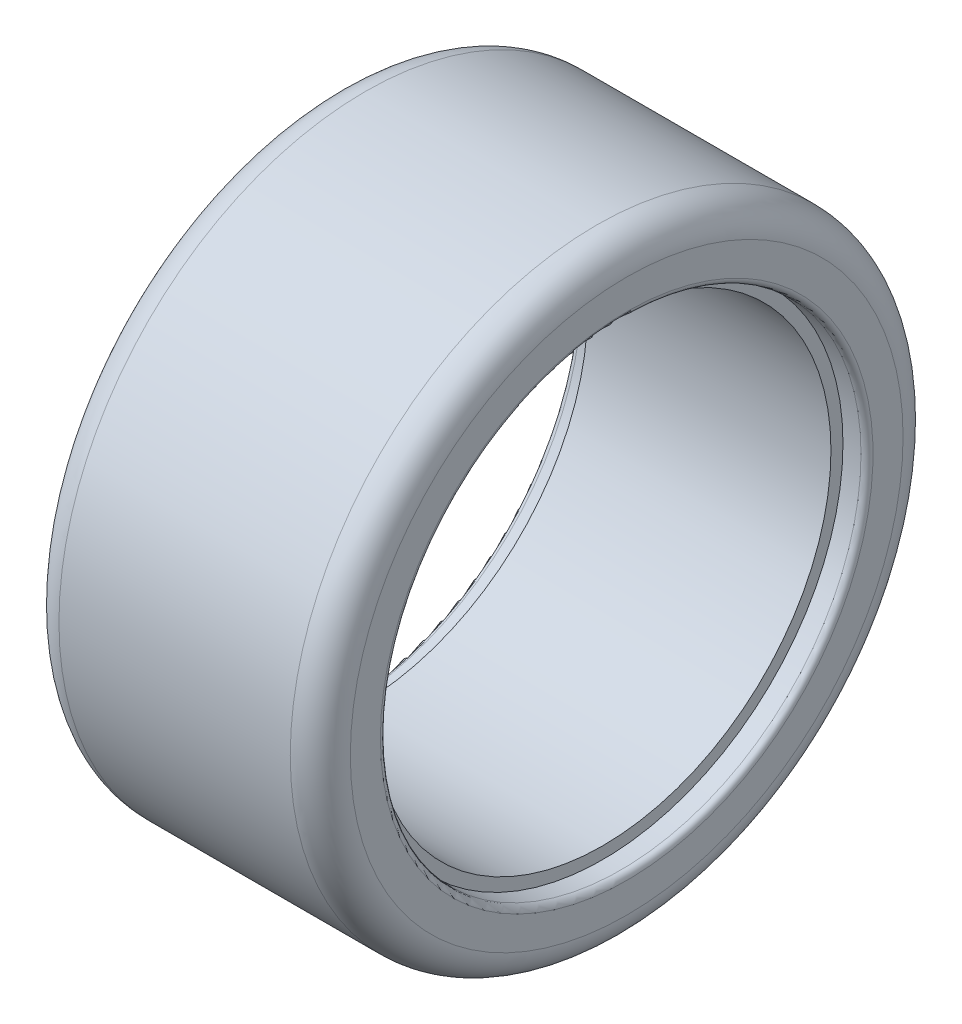
from build123d import *

# Parameters (mm, degrees)
FILLET1_R = 2.5
FILLET2_R = 0.5


with BuildPart() as part:
    # Sketch1 → Revolve1 (revolve)
    with BuildSketch(Plane(origin=(0, 0, 0), x_dir=(1, 0, 0), z_dir=(0, 1, 0))):
        Polygon((0, 19), (10.125, 19), (10.125, 20), (12.125, 20), (12.125, 25.5), (0, 25.5), align=None)
    revolve1 = revolve(axis=Axis((0, 0, 0), (1, 0, 0)))

    # Mirror1: Revolve1 across plane
    add(revolve1.mirror(Plane(origin=(0, 0, 0), x_dir=(0, 0, 1), z_dir=(1, 0, 0))))

    # Fillet1
    fillet1_edges = [part.edges().sort_by_distance(p)[0] for p in [
        (-12.125, 0, 25.5),
        (12.125, 0, 25.5),
    ]]
    fillet(fillet1_edges, radius=FILLET1_R)

    # Fillet2
    fillet2_edges = [part.edges().sort_by_distance(p)[0] for p in [
        (-12.125, 0, 20),
        (12.125, 0, 20),
    ]]
    fillet(fillet2_edges, radius=FILLET2_R)


solid = part.part
